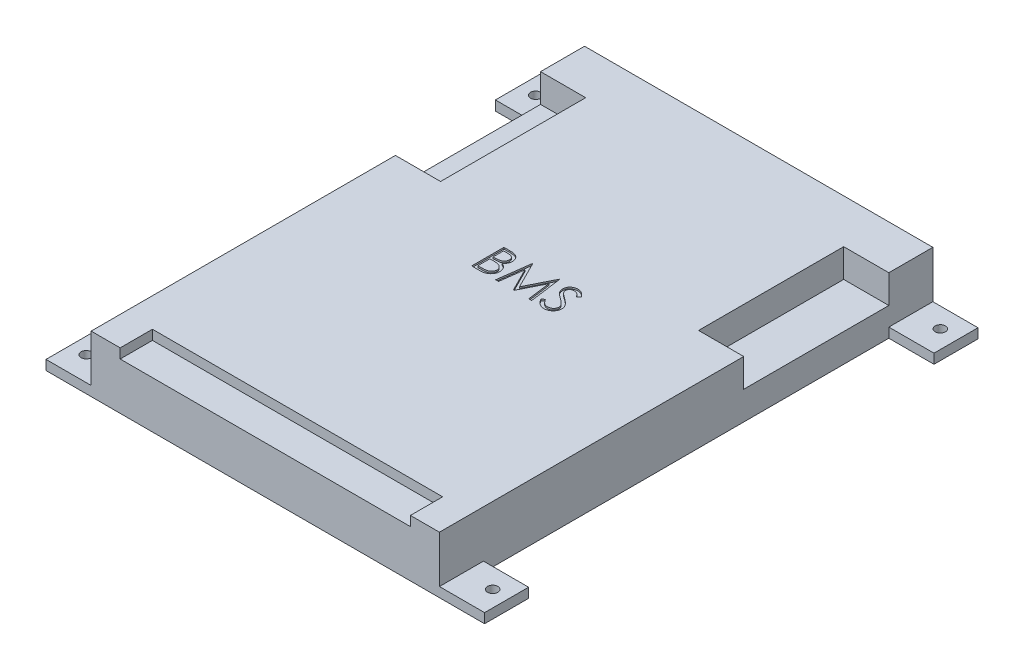
from build123d import *

# Parameters (mm, degrees)
BOSS_EXTRUDE1_DEPTH  = 3
BOSS_EXTRUDE3_DEPTH  = 14.6
SKETCH3_3_W          = 14
SKETCH3_3_H          = 45
BOSS_EXTRUDE4_DEPTH  = 5.8
M3_CLEARANCE_HOLE1_D = 3.2
CUT_EXTRUDE1_DEPTH   = 0.5
SKETCH8_W            = 90
SKETCH8_H            = 10
CUT_EXTRUDE2_DEPTH   = 3


with BuildPart() as part:
    # Sketch1 → Boss-Extrude1 (new body)
    with BuildSketch(Plane(origin=(0, 0, 0), x_dir=(1, 0, 0), z_dir=(0, 1, 0))):
        Polygon((0, 0), (0, 13.65), (14, 13.65), (14, 139.35), (0, 139.35), (0, 153), (136, 153), (136, 139.35), (122, 139.35), (122, 13.65), (136, 13.65), (136, 0), align=None)
    extrude(amount=BOSS_EXTRUDE1_DEPTH)

    # Sketch3 → Boss-Extrude3 (add)
    with BuildSketch(Plane(origin=(0, 3, 0), x_dir=(1, 0, 0), z_dir=(0, 1, 0))):
        Polygon((14, 94.35), (14, 0), (122, 0), (122, 94.35), (108, 94.35), (108, 139.35), (122, 139.35), (122, 153), (14, 153), (14, 139.35), (28, 139.35), (28, 94.35), align=None)
    extrude(amount=BOSS_EXTRUDE3_DEPTH)

    # Sketch3_3 → Boss-Extrude4 (add)
    with BuildSketch(Plane(origin=(0, 3, 0), x_dir=(1, 0, 0), z_dir=(0, 1, 0))):
        with Locations((21, 116.85)):
            Rectangle(SKETCH3_3_W, SKETCH3_3_H)
        with Locations((115, 116.85)):
            Rectangle(SKETCH3_3_W, SKETCH3_3_H)
    extrude(amount=BOSS_EXTRUDE4_DEPTH)

    # M3 Clearance Hole1 (through all)
    with Locations(Plane(origin=(0, 3, 0), x_dir=(1, 0, 0), z_dir=(0, 1, 0))):
        with Locations((5, 146.85), (130.458671537, 146.855744949), (131, 7.5), (5, 7.5)):
            Hole(M3_CLEARANCE_HOLE1_D / 2)

    # Sketch2 → Cut-Extrude1 (cut)
    with BuildSketch(Plane(origin=(0, 17.6, 0), x_dir=(1, 0, 0), z_dir=(0, 1, 0))):
        with BuildLine():
            Line((55.5, 86.5), (57.451121795, 86.5))
            add(Edge.make_bspline(
                [(57.451121795, 86.5), (57.546631733, 86.499497856), (57.731753762, 86.498524576), (58.000952167, 86.483429916), (58.253091626, 86.462848002), (58.488245262, 86.430190594), (58.706304411, 86.390785516), (58.907926232, 86.343066042), (59.092469581, 86.285847146), (59.312791685, 86.194857771), (59.563993574, 86.059648718), (59.835988981, 85.859852818), (60.068572522, 85.615474352), (60.269104857, 85.339809622), (60.428536628, 85.03656456), (60.543877477, 84.712966878), (60.616899978, 84.373190472), (60.62440979, 84.13992425), (60.628205128, 84.022035256)],
                knots=[0, 0, 0, 0, 1.001505555, 1.941167018, 2.826882275, 3.653841531, 4.429895133, 5.150066043, 5.825578002, 6.45369114, 7.647487171, 8.808567382, 9.977351308, 11.170798116, 12.373658725, 13.556498008, 14.765093433, 16, 16, 16, 16], degree=3))
            add(Edge.make_bspline(
                [(60.628205128, 84.022035256), (60.625081647, 83.911599383), (60.618943712, 83.694582477), (60.560250114, 83.377170736), (60.468362489, 83.075024397), (60.340633206, 82.789246153), (60.174627503, 82.526292972), (59.977889449, 82.284043641), (59.740527157, 82.072754907), (59.562689328, 81.954632328), (59.472355769, 81.89463141)],
                knots=[0, 0, 0, 0, 1.044552857, 2.05264487, 3.044412934, 4.028983338, 5.005914585, 5.980388656, 6.974128949, 8, 8, 8, 8], degree=3))
            add(Edge.make_bspline(
                [(59.472355769, 81.89463141), (59.585956991, 81.851017128), (59.803304269, 81.767572201), (60.102407162, 81.620042304), (60.360106719, 81.459579131), (60.578384279, 81.284345273), (60.765063293, 81.095462957), (60.928071697, 80.890162631), (61.067161338, 80.665766179), (61.18634112, 80.424613221), (61.279337565, 80.169166169), (61.348983006, 79.901821094), (61.388890004, 79.623536651), (61.394568979, 79.434149853), (61.397435897, 79.338541667)],
                knots=[0, 0, 0, 0, 1.27268992, 2.434971085, 3.483601985, 4.442670788, 5.356604649, 6.2567628, 7.179492994, 8.113709626, 9.066344395, 10.018646069, 10.999752585, 12, 12, 12, 12], degree=3))
            add(Edge.make_bspline(
                [(61.397435897, 79.338541667), (61.394644909, 79.240922032), (61.38915356, 79.048852666), (61.348639355, 78.766695139), (61.280041907, 78.497052434), (61.185552917, 78.238180484), (61.062232018, 77.990580099), (60.91215212, 77.753970774), (60.733204796, 77.530729829), (60.53302517, 77.31837662), (60.306561897, 77.127440085), (60.062231169, 76.957395209), (59.796955969, 76.817549317), (59.515093129, 76.70007497), (59.213480797, 76.610340117), (58.893473348, 76.547561334), (58.555346771, 76.505261229), (58.323318911, 76.5017835), (58.204326923, 76.5)],
                knots=[0, 0, 0, 0, 0.978564426, 1.925352924, 2.850884081, 3.763762016, 4.682927383, 5.618979971, 6.567305752, 7.547517671, 8.540179244, 9.531824382, 10.526200242, 11.540722885, 12.589160233, 13.674978461, 14.80764778, 16, 16, 16, 16], degree=3))
            Line((58.204326923, 76.5), (55.5, 76.5))
            Line((55.5, 76.5), (55.5, 86.5))
        make_face()
        with BuildLine():
            Line((56.397435897, 85.474358974), (56.397435897, 82.269230769))
            Line((56.397435897, 82.269230769), (57.000400641, 82.269230769))
            add(Edge.make_bspline(
                [(57.000400641, 82.269230769), (57.088540056, 82.270373406), (57.258843369, 82.272581214), (57.505471644, 82.278905549), (57.734400268, 82.296614244), (57.945234077, 82.31431785), (58.137641059, 82.343102386), (58.311194949, 82.377365595), (58.468619512, 82.413602466), (58.650161071, 82.475229572), (58.856083781, 82.566308644), (59.075606935, 82.707656747), (59.269133991, 82.876012042), (59.432554528, 83.070271932), (59.566301586, 83.284175321), (59.659197915, 83.514309265), (59.722190156, 83.754938213), (59.727880245, 83.920133221), (59.730769231, 84.00400641)],
                knots=[0, 0, 0, 0, 1.156816544, 2.235205308, 3.236616184, 4.169592532, 5.011045266, 5.787822928, 6.49130361, 7.128639758, 8.301311294, 9.436451833, 10.541879658, 11.654887649, 12.756523258, 13.837046038, 14.901820046, 16, 16, 16, 16], degree=3))
            add(Edge.make_bspline(
                [(59.730769231, 84.00400641), (59.729265859, 84.059508615), (59.726316831, 84.168382249), (59.702164537, 84.32709469), (59.661114325, 84.476362554), (59.608387773, 84.618231441), (59.534705805, 84.748265298), (59.447953053, 84.870960143), (59.343136795, 84.982137625), (59.223830187, 85.086050477), (59.086662693, 85.178177699), (58.931716145, 85.258865594), (58.756894211, 85.323839242), (58.565143196, 85.380742534), (58.353511518, 85.420709088), (58.124441365, 85.454004482), (57.876056454, 85.470955173), (57.704213304, 85.473199067), (57.615384615, 85.474358974)],
                knots=[0, 0, 0, 0, 0.91205012, 1.789085906, 2.630437955, 3.453916878, 4.269457761, 5.079663411, 5.91843418, 6.774407191, 7.675494373, 8.627863946, 9.638891023, 10.736472738, 11.911756761, 13.175263542, 14.539845004, 16, 16, 16, 16], degree=3))
            Line((57.615384615, 85.474358974), (56.397435897, 85.474358974))
        make_face(mode=Mode.SUBTRACT)
        with BuildLine():
            Line((56.397435897, 81.243589744), (56.397435897, 77.525641026))
            Line((56.397435897, 77.525641026), (57.675480769, 77.525641026))
            add(Edge.make_bspline(
                [(57.675480769, 77.525641026), (57.766963415, 77.526737447), (57.943284153, 77.528850654), (58.197859097, 77.535749381), (58.433810822, 77.551441598), (58.650062638, 77.576144025), (58.848949646, 77.602939594), (59.02808594, 77.638971825), (59.188923636, 77.68025457), (59.375421658, 77.74406649), (59.585431681, 77.843199265), (59.811748414, 77.992668483), (60.01296618, 78.170735076), (60.183838349, 78.376823403), (60.323875459, 78.600912908), (60.425748188, 78.838471051), (60.488579207, 79.085572558), (60.496185405, 79.254048879), (60.5, 79.338541667)],
                knots=[0, 0, 0, 0, 1.160039823, 2.235823828, 3.228722157, 4.157150951, 4.99529583, 5.772374946, 6.472645482, 7.099169577, 8.269452708, 9.405989375, 10.527446681, 11.663510218, 12.788923519, 13.866172445, 14.929861265, 16, 16, 16, 16], degree=3))
            add(Edge.make_bspline(
                [(60.5, 79.338541667), (60.49921113, 79.391379782), (60.497646116, 79.49620373), (60.474044359, 79.650248928), (60.439719017, 79.799465709), (60.395343491, 79.944259253), (60.330716443, 80.082011757), (60.255269171, 80.215447641), (60.166808023, 80.344743297), (60.02896755, 80.508206878), (59.828476165, 80.696541201), (59.543599664, 80.880934064), (59.219678813, 81.029642085), (58.984743119, 81.092783446), (58.86338141, 81.125400641)],
                knots=[0, 0, 0, 0, 0.723448775, 1.435228256, 2.130040452, 2.821711965, 3.505591119, 4.210454504, 4.921174351, 5.648778258, 7.137944449, 8.670945889, 10.280296675, 12, 12, 12, 12], degree=3))
            add(Edge.make_bspline(
                [(58.86338141, 81.125400641), (58.814726851, 81.135272309), (58.70923373, 81.156676123), (58.537212071, 81.179269561), (58.340823874, 81.199398304), (58.119615654, 81.214287326), (57.873307536, 81.22967745), (57.601373483, 81.235662653), (57.304924012, 81.242803396), (57.09923152, 81.243320923), (56.992387821, 81.243589744)],
                knots=[0, 0, 0, 0, 0.634451884, 1.375622551, 2.216452059, 3.157844607, 4.20941857, 5.370758133, 6.634282058, 8, 8, 8, 8], degree=3))
            Line((56.992387821, 81.243589744), (56.397435897, 81.243589744))
        make_face(mode=Mode.SUBTRACT)
        Polygon((62.935897436, 76.5), (64.256009615, 86.5), (64.384214744, 86.5), (68.512820513, 78.294871795), (72.629407051, 86.5), (72.757612179, 86.5), (74.08974359, 76.5), (73.192307692, 76.5), (72.230769231, 83.689503205), (68.622996795, 76.5), (68.418669872, 76.5), (64.794871795, 83.711538462), (63.839342949, 76.5), align=None)
        with BuildLine():
            Line((75.115384615, 78.429086538), (75.960737179, 78.935897436))
            add(Edge.make_bspline(
                [(75.960737179, 78.935897436), (76.039360714, 78.804284907), (76.190000373, 78.552120382), (76.441289971, 78.211383124), (76.701669717, 77.921776961), (76.973067813, 77.684986654), (77.253827665, 77.498561264), (77.545782104, 77.366554887), (77.847947278, 77.284223529), (78.053586767, 77.274223282), (78.15625, 77.269230769)],
                knots=[0, 0, 0, 0, 1.272034388, 2.437168799, 3.508375237, 4.49857839, 5.41946034, 6.295179144, 7.148887113, 8, 8, 8, 8], degree=3))
            add(Edge.make_bspline(
                [(78.15625, 77.269230769), (78.243926744, 77.271672691), (78.417746096, 77.276513806), (78.673638219, 77.323030383), (78.922157654, 77.394493608), (79.158182333, 77.496839127), (79.378455517, 77.620663372), (79.571617504, 77.770223879), (79.738606399, 77.937670181), (79.875203869, 78.124477766), (79.98000397, 78.325383905), (80.060552737, 78.531600909), (80.105252947, 78.746368247), (80.111986528, 78.890969569), (80.115384615, 78.963942308)],
                knots=[0, 0, 0, 0, 1.095163259, 2.171163733, 3.241058638, 4.321873601, 5.38011039, 6.391990106, 7.366004449, 8.327778327, 9.272591725, 10.192022065, 11.087607919, 12, 12, 12, 12], degree=3))
            add(Edge.make_bspline(
                [(80.115384615, 78.963942308), (80.111172299, 79.047201878), (80.102609276, 79.216456419), (80.030233618, 79.466169713), (79.916378627, 79.713291342), (79.811342502, 79.8661521), (79.756810897, 79.945512821)],
                knots=[0, 0, 0, 0, 0.938893495, 1.908633276, 2.914225137, 4, 4, 4, 4], degree=3))
            add(Edge.make_bspline(
                [(79.756810897, 79.945512821), (79.712037714, 80.002789459), (79.618042016, 80.123034598), (79.456449123, 80.302020985), (79.266831654, 80.486645039), (79.055678639, 80.683956631), (78.815298386, 80.884778907), (78.553219773, 81.098688272), (78.262751605, 81.317549921), (78.059038757, 81.46432868), (77.953926282, 81.540064103)],
                knots=[0, 0, 0, 0, 0.722233717, 1.516239348, 2.393582979, 3.351407094, 4.387010283, 5.505090956, 6.712668013, 8, 8, 8, 8], degree=3))
            add(Edge.make_bspline(
                [(77.953926282, 81.540064103), (77.848714864, 81.615002924), (77.647558646, 81.758280245), (77.36624841, 81.970921057), (77.114692802, 82.165332112), (76.894009897, 82.343343575), (76.704296764, 82.504979589), (76.544058446, 82.648687987), (76.417376855, 82.778355303), (76.346932338, 82.862473423), (76.315304487, 82.900240385)],
                knots=[0, 0, 0, 0, 1.452282411, 2.77665338, 3.964542531, 5.026858415, 5.96415736, 6.766646006, 7.446254459, 8, 8, 8, 8], degree=3))
            add(Edge.make_bspline(
                [(76.315304487, 82.900240385), (76.271097215, 82.95910049), (76.184157682, 83.074856786), (76.069397666, 83.255784951), (75.971857201, 83.440994281), (75.895393395, 83.630982466), (75.831004198, 83.823082262), (75.787695825, 84.019800107), (75.760577548, 84.220253303), (75.757800443, 84.355149019), (75.756410256, 84.422676282)],
                knots=[0, 0, 0, 0, 1.068054152, 2.10047183, 3.106115577, 4.101338837, 5.06977816, 6.043150881, 7.020423561, 8, 8, 8, 8], degree=3))
            add(Edge.make_bspline(
                [(75.756410256, 84.422676282), (75.760139425, 84.528475638), (75.767518054, 84.737812963), (75.829919532, 85.043615336), (75.928413513, 85.335576528), (76.066398907, 85.610806053), (76.244277059, 85.862137427), (76.4501227, 86.092461675), (76.695298375, 86.286086196), (76.96430587, 86.455263505), (77.258752647, 86.587680435), (77.567298085, 86.687568949), (77.890432577, 86.744166828), (78.109298676, 86.752289014), (78.220352564, 86.756410256)],
                knots=[0, 0, 0, 0, 1.005424448, 1.989358655, 2.955360095, 3.929531133, 4.905563448, 5.876582895, 6.856512386, 7.866279853, 8.892233794, 9.918561126, 10.94386622, 12, 12, 12, 12], degree=3))
            add(Edge.make_bspline(
                [(78.220352564, 86.756410256), (78.338192851, 86.752345823), (78.57253957, 86.744262963), (78.917251614, 86.673984302), (79.249139376, 86.557696668), (79.516120132, 86.425729074), (79.725070879, 86.293925029), (79.884421544, 86.173868388), (80.045899975, 86.035653792), (80.210808703, 85.878913089), (80.376353444, 85.702208086), (80.544991879, 85.506748975), (80.717118362, 85.293730244), (80.82784939, 85.141660242), (80.884615385, 85.063701923)],
                knots=[0, 0, 0, 0, 1.286793592, 2.559021753, 3.825965368, 5.121522368, 5.803751409, 6.523245864, 7.299691795, 8.125521123, 9.008227632, 9.944561021, 10.946284179, 12, 12, 12, 12], degree=3))
            Line((80.884615385, 85.063701923), (80.073317308, 84.448717949))
            add(Edge.make_bspline(
                [(80.073317308, 84.448717949), (80.024328929, 84.511828493), (79.929988766, 84.633364645), (79.786761661, 84.803568404), (79.651765524, 84.95904406), (79.518764382, 85.094087282), (79.394782577, 85.216093378), (79.274448171, 85.320549826), (79.159492882, 85.408480098), (79.014587423, 85.502318841), (78.832536799, 85.595337423), (78.604009553, 85.674049074), (78.365191624, 85.721349251), (78.202535534, 85.727603216), (78.120192308, 85.730769231)],
                knots=[0, 0, 0, 0, 1.181633172, 2.275549214, 3.290209073, 4.226197932, 5.078386478, 5.862611352, 6.581680152, 7.217281963, 8.414376989, 9.595101626, 10.782541182, 12, 12, 12, 12], degree=3))
            add(Edge.make_bspline(
                [(78.120192308, 85.730769231), (78.016887958, 85.727307231), (77.817675251, 85.72063109), (77.534846005, 85.647716847), (77.280291933, 85.532911531), (77.061570319, 85.372011594), (76.87946467, 85.181380186), (76.747734788, 84.962012029), (76.668448604, 84.719776593), (76.658773519, 84.550800432), (76.653846154, 84.46474359)],
                knots=[0, 0, 0, 0, 1.14458467, 2.207223713, 3.21896685, 4.227309161, 5.202851033, 6.127160689, 7.046193047, 8, 8, 8, 8], degree=3))
            add(Edge.make_bspline(
                [(76.653846154, 84.46474359), (76.654969373, 84.411167937), (76.657217647, 84.303929024), (76.688574212, 84.14549639), (76.728858009, 83.987463992), (76.7926941, 83.830542326), (76.880823539, 83.671987015), (76.996552613, 83.509067765), (77.142304933, 83.340348597), (77.25395354, 83.230613243), (77.312900641, 83.172676282)],
                knots=[0, 0, 0, 0, 0.858281714, 1.717966888, 2.583508476, 3.4729293, 4.427298488, 5.488583878, 6.674047936, 8, 8, 8, 8], degree=3))
            add(Edge.make_bspline(
                [(77.312900641, 83.172676282), (77.334790276, 83.153141923), (77.38679504, 83.106732756), (77.481869113, 83.030754811), (77.607419965, 82.937032605), (77.760169112, 82.821068843), (77.942933002, 82.68655038), (78.155731734, 82.535197203), (78.396193256, 82.362095891), (78.566827302, 82.241074346), (78.657051282, 82.177083333)],
                knots=[0, 0, 0, 0, 0.420754252, 0.999615792, 1.744751191, 2.668019286, 3.750313428, 4.999500688, 6.413464383, 8, 8, 8, 8], degree=3))
            add(Edge.make_bspline(
                [(78.657051282, 82.177083333), (78.765582463, 82.09810802), (78.975738053, 81.945183272), (79.274759709, 81.715424187), (79.545884875, 81.490716276), (79.790065457, 81.272494542), (80.009713767, 81.062414276), (80.202392969, 80.857948047), (80.370066341, 80.660560696), (80.550578394, 80.407496194), (80.735029307, 80.096693096), (80.893433614, 79.715898129), (80.993314607, 79.333622928), (81.006376079, 79.076689109), (81.012820513, 78.949919872)],
                knots=[0, 0, 0, 0, 1.163667725, 2.253281268, 3.268753668, 4.215851969, 5.092017293, 5.902905408, 6.650798638, 7.335211899, 8.59617414, 9.77448103, 10.901945474, 12, 12, 12, 12], degree=3))
            add(Edge.make_bspline(
                [(81.012820513, 78.949919872), (81.010942975, 78.8602674), (81.007224361, 78.682703447), (80.964478893, 78.421974656), (80.901851278, 78.1687436), (80.807459181, 77.926140421), (80.692250158, 77.689726814), (80.546060878, 77.465704241), (80.37661035, 77.249114531), (80.182228165, 77.045733127), (79.969525587, 76.85902971), (79.74471503, 76.692946677), (79.507428536, 76.554465753), (79.258953346, 76.441463347), (78.999232384, 76.353081869), (78.728353001, 76.2890451), (78.445868684, 76.249743068), (78.253867308, 76.24566375), (78.15625, 76.243589744)],
                knots=[0, 0, 0, 0, 0.983748083, 1.948392443, 2.894712957, 3.844097841, 4.80183111, 5.778335162, 6.776009319, 7.81870978, 8.863265674, 9.881300176, 10.883814829, 11.87499822, 12.874611388, 13.892143829, 14.928324115, 16, 16, 16, 16], degree=3))
            add(Edge.make_bspline(
                [(78.15625, 76.243589744), (78.080720449, 76.245050262), (77.930612563, 76.247952906), (77.708585472, 76.273613708), (77.491043788, 76.309919718), (77.280717268, 76.367559918), (77.074896092, 76.437494138), (76.874475422, 76.52360366), (76.679358125, 76.626795664), (76.488450746, 76.744781448), (76.302238818, 76.88208929), (76.12246891, 77.042013566), (75.943242666, 77.22014358), (75.769850105, 77.421316618), (75.598783978, 77.642282569), (75.433417094, 77.885108807), (75.270326472, 78.148472675), (75.167996564, 78.333801492), (75.115384615, 78.429086538)],
                knots=[0, 0, 0, 0, 0.915332311, 1.819136955, 2.706846663, 3.586547465, 4.459518054, 5.340707479, 6.227863349, 7.133153174, 8.059268498, 9.028702269, 10.047606654, 11.120612155, 12.245963614, 13.433783089, 14.680604001, 16, 16, 16, 16], degree=3))
        make_face()
    extrude(amount=-CUT_EXTRUDE1_DEPTH, mode=Mode.SUBTRACT)

    # Sketch8 → Cut-Extrude2 (cut)
    with BuildSketch(Plane(origin=(0, 17.6, 0), x_dir=(1, 0, 0), z_dir=(0, 1, 0))):
        with Locations((68, 5)):
            Rectangle(SKETCH8_W, SKETCH8_H)
    extrude(amount=-CUT_EXTRUDE2_DEPTH, mode=Mode.SUBTRACT)


solid = part.part
